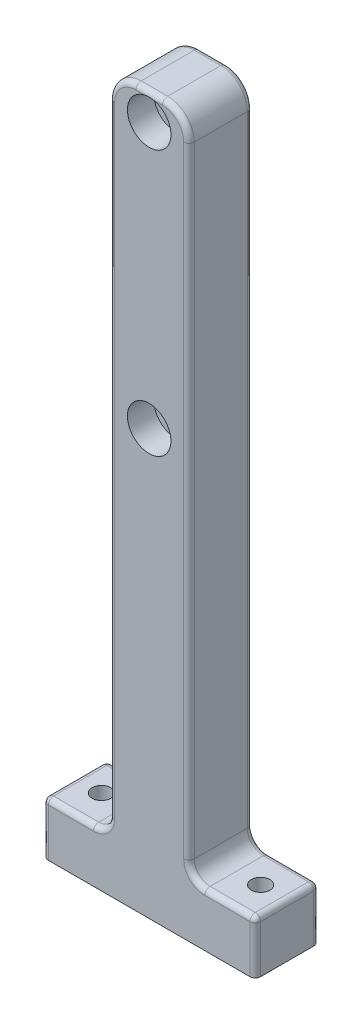
from build123d import *

# Parameters (mm, degrees)
SKETCH_1_W          = 15
SKETCH_1_H          = 135
SKETCH_1_W_2        = 40
SKETCH_1_H_2        = 10
EXTRUDE_1_DEPTH     = 12
SKETCH_3_R          = 1.75
CUT_EXTRUDE_1_DEPTH = 128.157382798
FILLET_1_R          = 3
FILLET_2_R          = 5
FILLET_3_R          = 1
SKETCH_2_R          = 4.1
CUT_EXTRUDE_2_DEPTH = 5


with BuildPart() as part:
    # ｽｹｯﾁ1 → ﾎﾞｽ - 押し出し1 (new body)
    with BuildSketch(Plane.XY):
        Rectangle(SKETCH_1_W, SKETCH_1_H)
        with Locations((0, -62.5)):
            Rectangle(SKETCH_1_W_2, SKETCH_1_H_2)
    extrude(amount=EXTRUDE_1_DEPTH)

    # ｽｹｯﾁ3 → ｶｯﾄ - 押し出し1 (cut, through all)
    with BuildSketch(Plane(origin=(0, -57.5, 0), x_dir=(1, 0, 0), z_dir=(0, 1, 0))):
        with Locations(Location((-15, -6, 0), (0, 0, 270))):
            Circle(SKETCH_3_R)
        with Locations(Location((15, -6, 0), (0, 0, 270))):
            Circle(SKETCH_3_R)
    extrude(amount=-CUT_EXTRUDE_1_DEPTH, mode=Mode.SUBTRACT)

    # ﾌｨﾚｯﾄ1
    fillet_1_edges = [part.edges().sort_by_distance(p)[0] for p in [
        (-7.5, -57.5, 6),
        (7.5, -57.5, 6),
    ]]
    fillet(fillet_1_edges, radius=FILLET_1_R)

    # ﾌｨﾚｯﾄ2
    fillet_2_edges = [part.edges().sort_by_distance(p)[0] for p in [
        (7.5, 67.5, 6),
        (-7.5, 67.5, 6),
    ]]
    fillet(fillet_2_edges, radius=FILLET_2_R)

    # ﾌｨﾚｯﾄ3
    fillet_3_edges = [part.edges().sort_by_distance(p)[0] for p in [
        (20, -57.5, 6),
        (-20, -57.5, 6),
        (-15.25, -57.5, 12),
        (20, -62.5, 12),
        (-20, -62.5, 12),
        (-15.25, -57.5, 0),
        (20, -62.5, 0),
        (-20, -62.5, 0),
        (7.5, 4, 12),
        (7.5, 4, 0),
        (15.25, -57.5, 12),
        (15.25, -57.5, 0),
        (-7.5, 4, 12),
        (-7.5, 4, 0),
        (8.378679656, -56.621320344, 0),
        (8.378679656, -56.621320344, 12),
        (-8.378679656, -56.621320344, 0),
        (-8.378679656, -56.621320344, 12),
        (0, 67.5, 0),
        (0, 67.5, 12),
        (-6.035533906, 66.035533906, 0),
        (6.035533906, 66.035533906, 0),
        (-6.035533906, 66.035533906, 12),
        (6.035533906, 66.035533906, 12),
    ]]
    fillet(fillet_3_edges, radius=FILLET_3_R)

    # ｽｹｯﾁ2 → ｶｯﾄ - 押し出し2 (cut)
    with BuildSketch(Plane.XY.offset(12)):
        with Locations((0, 12.5)):
            Circle(SKETCH_2_R)
        with Locations((0, 62.5)):
            Circle(SKETCH_2_R)
    extrude(amount=-CUT_EXTRUDE_2_DEPTH, mode=Mode.SUBTRACT)


solid = part.part
